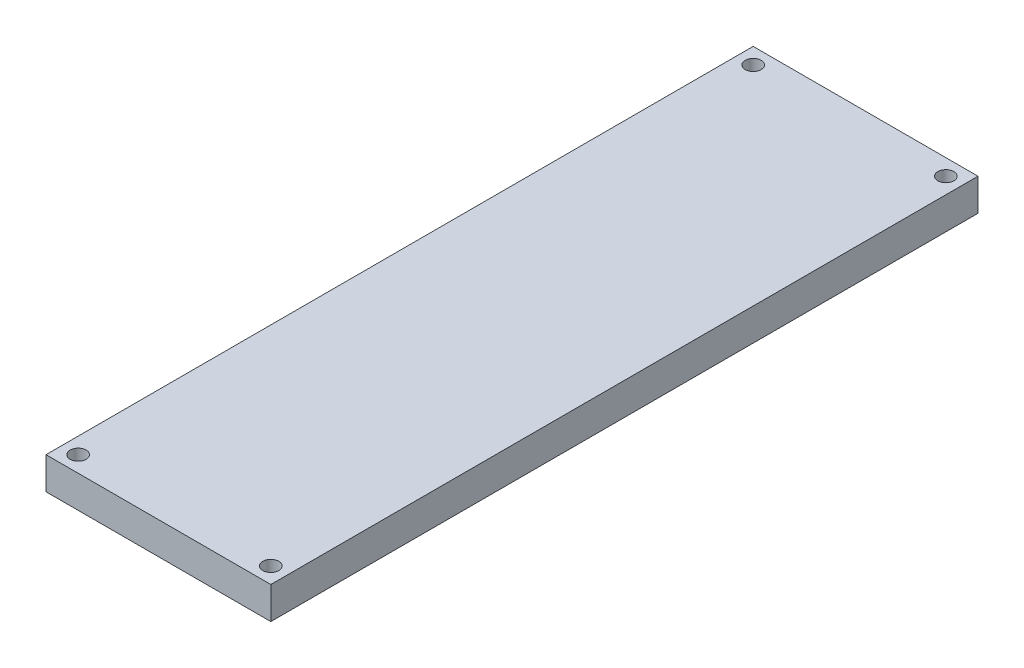
from build123d import *

# Parameters (mm, degrees)
SKETCH1_W                                       = 88.827290182
SKETCH1_H                                       = 279.4
BASE_SHAPE_DEPTH                                = 12.7
SKETCH2_R                                       = 3.175
F_0_25_DIAMETER_CLEARANCE_HOLES_FOR_ASSEM_DEPTH = 12.7


with BuildPart() as part:
    # Sketch1 → Base Shape (new body)
    with BuildSketch(Plane(origin=(0, 0, 0), x_dir=(1, 0, 0), z_dir=(0, 1, 0))):
        Rectangle(SKETCH1_W, SKETCH1_H)
    extrude(amount=BASE_SHAPE_DEPTH)

    # Sketch2 → 0.25" Diameter Clearance Holes for Assembly (cut)
    with BuildSketch(Plane(origin=(0, 12.7, 0), x_dir=(1, 0, 0), z_dir=(0, 1, 0))):
        with Locations((-38.063645091, -133.35)):
            Circle(SKETCH2_R)
        with Locations((38.063645091, -133.35)):
            Circle(SKETCH2_R)
        with Locations((-38.063645091, 133.35)):
            Circle(SKETCH2_R)
        with Locations((38.063645091, 133.35)):
            Circle(SKETCH2_R)
    extrude(amount=-F_0_25_DIAMETER_CLEARANCE_HOLES_FOR_ASSEM_DEPTH, mode=Mode.SUBTRACT)


solid = part.part
